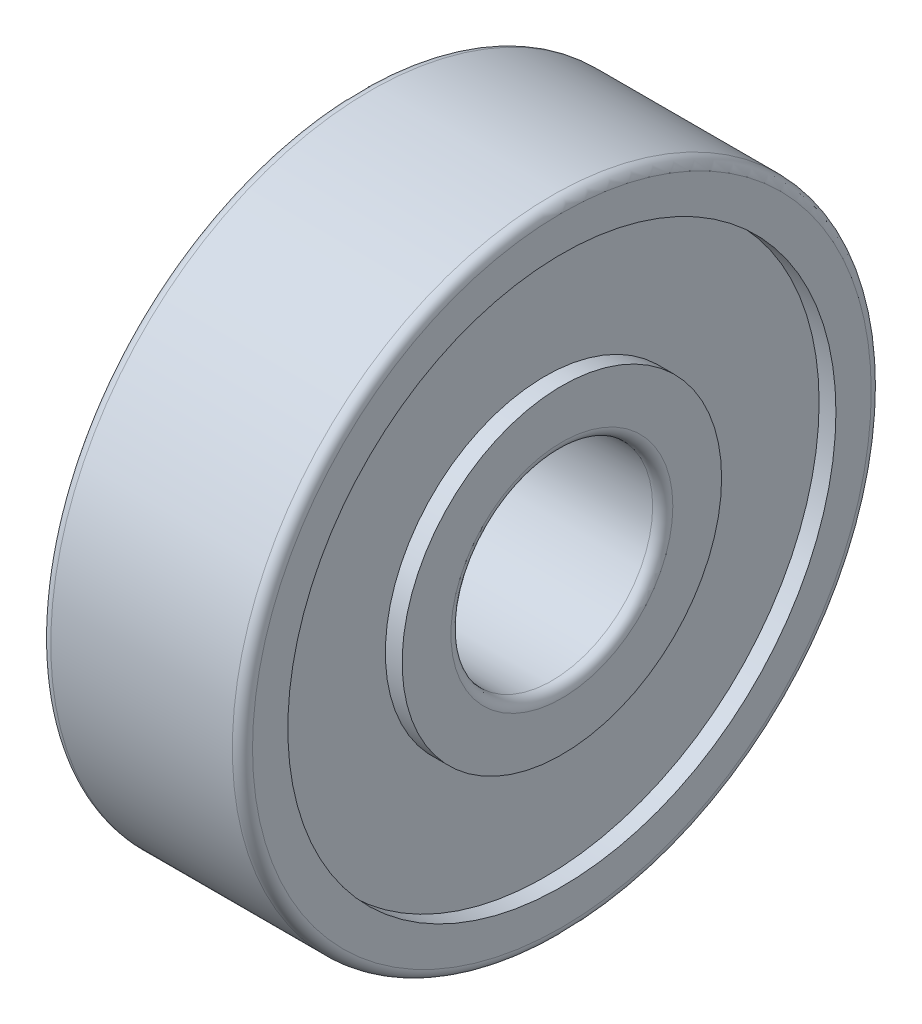
from build123d import *


with BuildPart() as part:
    # Sketch1 → Revolve1 (revolve)
    with BuildSketch(Plane.XY):
        with BuildLine():
            Line((0, 4.75), (0, 3.3))
            ThreePointArc((0, 3.3), (0.087867966, 3.087867966), (0.3, 3))
            Line((0.3, 3), (5.7, 3))
            ThreePointArc((5.7, 3), (5.912132034, 3.087867966), (6, 3.3))
            Line((6, 3.3), (6, 4.75))
            Line((6, 4.75), (5.5, 4.75))
            Line((5.5, 4.75), (5.5, 8.15))
            Line((5.5, 8.15), (6, 8.15))
            Line((6, 8.15), (6, 9.2))
            ThreePointArc((6, 9.2), (5.912132034, 9.412132034), (5.7, 9.5))
            Line((5.7, 9.5), (0.3, 9.5))
            ThreePointArc((0.3, 9.5), (0.087867966, 9.412132034), (0, 9.2))
            Line((0, 9.2), (0, 8.15))
            Line((0, 8.15), (0.5, 8.15))
            Line((0.5, 8.15), (0.5, 4.75))
            Line((0.5, 4.75), (0, 4.75))
        make_face()
    revolve(axis=Axis((-0.001375773, 0, 0), (1, 0, 0)))


solid = part.part
